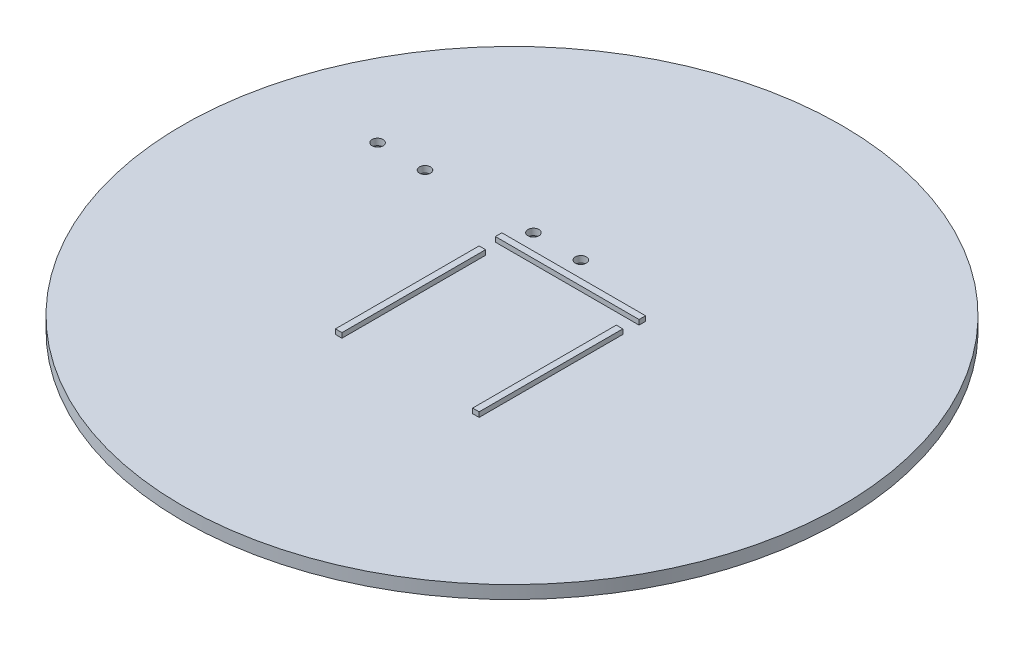
from build123d import *

# Parameters (mm, degrees)
SKETCH2_R           = 101.5
BOSS_EXTRUDE2_DEPTH = 2
SKETCH4_W           = 44.25
SKETCH4_H           = 2
SKETCH4_W_2         = 2
SKETCH4_H_2         = 44.25
BOSS_EXTRUDE3_DEPTH = 1.5
SKETCH5_R           = 1.7
CUT_EXTRUDE1_DEPTH  = 5
CUT_EXTRUDE2_DEPTH  = 2


with BuildPart() as part:
    # Sketch2 → Boss-Extrude2 (new body, symmetric)
    with BuildSketch(Plane(origin=(0, 0, 0), x_dir=(1, 0, 0), z_dir=(0, 1, 0))):
        Circle(SKETCH2_R)
    extrude(amount=BOSS_EXTRUDE2_DEPTH, both=True)

    # Sketch4 → Boss-Extrude3 (add, symmetric)
    with BuildSketch(Plane(origin=(0, 2, 0), x_dir=(1, 0, 0), z_dir=(0, 1, 0))):
        with Locations((0, 18)):
            Rectangle(SKETCH4_W, SKETCH4_H)
        with Locations((-21.125, -10.125)):
            Rectangle(SKETCH4_W_2, SKETCH4_H_2)
        with Locations((21.125, -10.125)):
            Rectangle(SKETCH4_W_2, SKETCH4_H_2)
    extrude(amount=BOSS_EXTRUDE3_DEPTH, both=True)

    # Sketch5 → Cut-Extrude1 (cut, through all)
    with BuildSketch(Plane(origin=(0, 2, 0), x_dir=(1, 0, 0), z_dir=(0, 1, 0))):
        with Locations((-66.8, 25.4)):
            Circle(SKETCH5_R)
        with Locations((-52.2, 25.4)):
            Circle(SKETCH5_R)
        with Locations((-18.8, 25.4)):
            Circle(SKETCH5_R)
        with Locations((-4.2, 25.4)):
            Circle(SKETCH5_R)
    extrude(amount=-CUT_EXTRUDE1_DEPTH, mode=Mode.SUBTRACT)

    # Sketch6 → Cut-Extrude2 (cut)
    with BuildSketch(Plane(origin=(0, -2, 0), x_dir=(-1, 0, 0), z_dir=(0, -1, 0))):
        Polygon((7.490896534, 25.4), (5.845448267, 28.25), (2.554551733, 28.25), (0.909103466, 25.4), (2.554551733, 22.55), (5.845448267, 22.55), align=None)
        Polygon((22.090896534, 25.4), (20.445448267, 28.25), (17.154551733, 28.25), (15.509103466, 25.4), (17.154551733, 22.55), (20.445448267, 22.55), align=None)
        Polygon((55.490896534, 25.4), (53.845448267, 28.25), (50.554551733, 28.25), (48.909103466, 25.4), (50.554551733, 22.55), (53.845448267, 22.55), align=None)
        Polygon((70.090896534, 25.4), (68.445448267, 28.25), (65.154551733, 28.25), (63.509103466, 25.4), (65.154551733, 22.55), (68.445448267, 22.55), align=None)
    extrude(amount=-CUT_EXTRUDE2_DEPTH, mode=Mode.SUBTRACT)


solid = part.part
